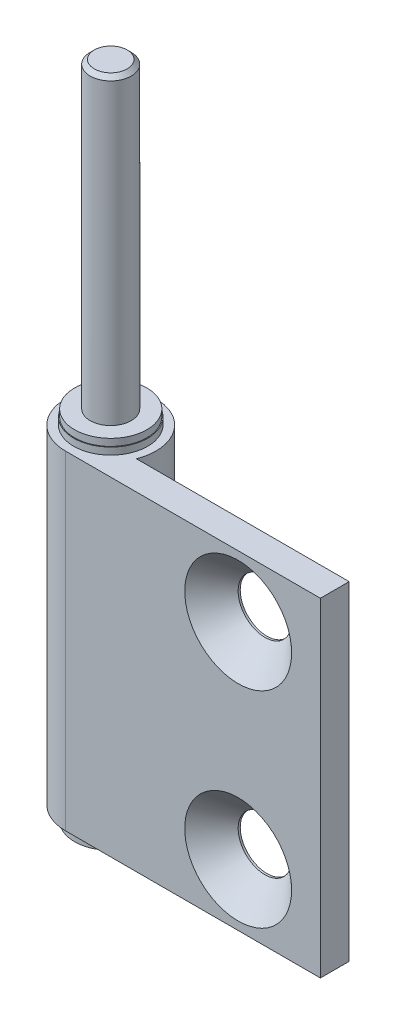
from build123d import *

# Parameters (mm, degrees)
EXTRUDE1_DEPTH       = 40
HOLEWZD1_D           = 6.5
HOLEWZD1_DEPTH       = 11
HOLEWZD1_CSINK_D     = 13
HOLEWZD1_CSINK_ANGLE = 90
CHAMFER1_SIZE        = 0.5


with BuildPart() as part:
    # Sketch1 → Extrude1 (new body)
    with BuildSketch(Plane.XZ.offset(41.7)):
        with BuildLine():
            Line((31, 5.5), (0, 5.5))
            ThreePointArc((0, 5.5), (-3.102418411, -4.541475531), (5.123475383, 2))
            Line((5.123475383, 2), (31, 2))
            Line((31, 2), (31, 5.5))
        make_face()
    extrude(amount=-EXTRUDE1_DEPTH)

    # Sketch2 → Revolve1 (revolve)
    with BuildSketch(Plane.XY):
        Polygon((2.5, 36.8), (0, 36.8), (0, -1.7), (4.5, -1.7), (4.5, -0.85), (4.4, -0.85), (4.4, 0), (2.5, 0), align=None)
    revolve(axis=Axis((0, 36.8, 0), (0, -1, 0)))

    # Sketch3 → Revolve2 (revolve)
    with BuildSketch(Plane.XY):
        Polygon((4.5, -41.7), (0, -41.7), (0, -44.9), (2.5, -44.9), (2.5, -43.4), (4.4, -43.4), (4.4, -42.55), (4.5, -42.55), align=None)
    revolve(axis=Axis((0, -41.7, 0), (0, -1, 0)))

    # HoleWzd1
    with Locations(Plane.XY.offset(5.5)):
        with Locations((21, -34.2), (21, -9.2)):
            CounterSinkHole(HOLEWZD1_D / 2, HOLEWZD1_CSINK_D / 2, depth=HOLEWZD1_DEPTH, counter_sink_angle=HOLEWZD1_CSINK_ANGLE)

    # Chamfer1
    chamfer1_edges = [part.edges().sort_by_distance(p)[0] for p in [
        (-2.5, 36.8, 0),
        (-2.5, -44.9, 0),
    ]]
    chamfer(chamfer1_edges, length=CHAMFER1_SIZE)


solid = part.part
